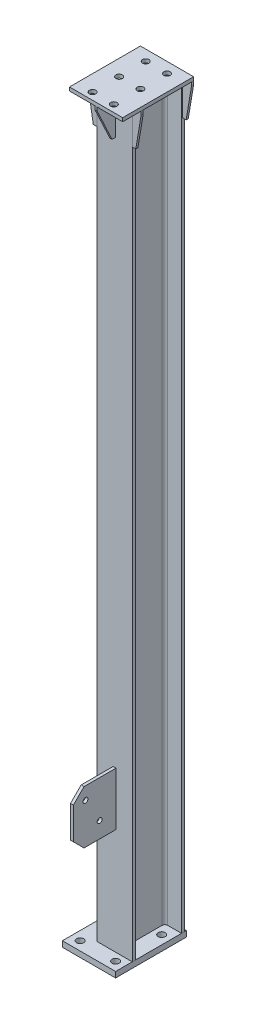
from build123d import *

# Parameters (mm, degrees)
H_HM150_100_1_DEPTH = 2100
SKETCH_12_W         = 150
SKETCH_12_H         = 200
EXTRUDE_1_DEPTH     = 16
SKETCH_13_W         = 148
SKETCH_13_H         = 10
CUT_EXTRUDE_1_DEPTH = 100
SKETCH_14_W         = 150
SKETCH_14_H         = 200
EXTRUDE_2_DEPTH     = 10
SKETCH_16_R         = 9
CUT_EXTRUDE_2_DEPTH = 10
EXTRUDE_3_DEPTH     = 6
EXTRUDE_3_2_DEPTH   = 6
EXTRUDE_4_DEPTH     = 6
EXTRUDE_4_2_DEPTH   = 6
EXTRUDE_5_DEPTH     = 6
SKETCH_20_W         = 8
SKETCH_20_H         = 150
EXTRUDE_6_DEPTH     = 120
CHAMFER_1_SIZE      = 30
SKETCH_21_R         = 7
CUT_EXTRUDE_3_DEPTH = 8
SKETCH_22_W         = 159
SKETCH_22_H         = 150
EXTRUDE_7_DEPTH     = 8
CHAMFER_2_SIZE      = 30
SKETCH_23_R         = 7
CUT_EXTRUDE_4_DEPTH = 8
SKETCH_24_R         = 10
CUT_EXTRUDE_5_DEPTH = 16


with BuildPart() as part:
    # 草图11 → H型钢 HM150×100(1) (new body)
    with BuildSketch(Plane(origin=(-50, -1126.815903712, 4951.12717578), x_dir=(1, 0, 0), z_dir=(0, -1, 0))):
        with BuildLine():
            Line((-50, -74), (50, -74))
            Line((50, -74), (50, -65))
            Line((50, -65), (11, -65))
            ThreePointArc((11, -65), (5.343145751, -62.656854249), (3, -57))
            Line((3, -57), (3, 57))
            ThreePointArc((3, 57), (5.343145751, 62.656854249), (11, 65))
            Line((11, 65), (50, 65))
            Line((50, 65), (50, 74))
            Line((50, 74), (-50, 74))
            Line((-50, 74), (-50, 65))
            Line((-50, 65), (-11, 65))
            ThreePointArc((-11, 65), (-5.343145751, 62.656854249), (-3, 57))
            Line((-3, 57), (-3, -57))
            ThreePointArc((-3, -57), (-5.343145751, -62.656854249), (-11, -65))
            Line((-11, -65), (-50, -65))
            Line((-50, -65), (-50, -74))
        make_face()
    extrude(amount=H_HM150_100_1_DEPTH)

    # 草图13 → 切除-拉伸1 (cut)
    with BuildSketch(Plane.ZY.offset(100)):
        with Locations((4951.12717578, -1131.815903712)):
            Rectangle(SKETCH_13_W, SKETCH_13_H)
    extrude(amount=-CUT_EXTRUDE_1_DEPTH, mode=Mode.SUBTRACT)


with BuildPart() as body_2:
    # 草图12 → 凸台-拉伸1 (new body)
    with BuildSketch(Plane.XZ.offset(3226.815903712)):
        with Locations((-75, 4972.12717578)):
            Rectangle(SKETCH_12_W, SKETCH_12_H)
    extrude(amount=EXTRUDE_1_DEPTH)

    # 草图24 → 切除-拉伸5 (cut)
    with BuildSketch(Plane.XZ.offset(3242.815903712)):
        with Locations(Location((-125, 5047.12717578, 0), (0, 0, 270))):
            Circle(SKETCH_24_R)
        with Locations(Location((-25, 5047.12717578, 0), (0, 0, 270))):
            Circle(SKETCH_24_R)
        with Locations(Location((-125, 4917.12717578, 0), (0, 0, 270))):
            Circle(SKETCH_24_R)
        with Locations(Location((-25, 4917.12717578, 0), (0, 0, 270))):
            Circle(SKETCH_24_R)
    extrude(amount=-CUT_EXTRUDE_5_DEPTH, mode=Mode.SUBTRACT)


with BuildPart() as body_3:
    # 草图14 → 凸台-拉伸2 (new body)
    with BuildSketch(Plane(origin=(0, -1136.815903712, 0), x_dir=(1, 0, 0), z_dir=(0, 1, 0))):
        with Locations((-50, -4977.12717578)):
            Rectangle(SKETCH_14_W, SKETCH_14_H)
    extrude(amount=EXTRUDE_2_DEPTH)

    # 草图16 → 切除-拉伸2 (cut)
    with BuildSketch(Plane(origin=(0, -1126.815903712, 0), x_dir=(1, 0, 0), z_dir=(0, 1, 0))):
        with Locations(Location((-20, -4907.12717578, 0), (0, 0, 270))):
            Circle(SKETCH_16_R)
        with Locations(Location((-20, -4982.12717578, 0), (0, 0, 270))):
            Circle(SKETCH_16_R)
        with Locations(Location((-20, -5057.12717578, 0), (0, 0, 270))):
            Circle(SKETCH_16_R)
        with Locations(Location((-80, -4907.12717578, 0), (0, 0, 270))):
            Circle(SKETCH_16_R)
        with Locations(Location((-80, -4982.12717578, 0), (0, 0, 270))):
            Circle(SKETCH_16_R)
        with Locations(Location((-80, -5057.12717578, 0), (0, 0, 270))):
            Circle(SKETCH_16_R)
    extrude(amount=-CUT_EXTRUDE_2_DEPTH, mode=Mode.SUBTRACT)


with BuildPart() as body_4:
    # 草图17 → 凸台-拉伸3 (new body)
    with BuildSketch(Plane(origin=(0, 0, 4877.12717578), x_dir=(-1, 0, 0), z_dir=(0, 0, -1))):
        Polygon((0, -1136.815903712), (-25, -1136.815903712), (-25, -1146.815903712), (-10, -1236.815903712), (0, -1236.815903712), align=None)
    extrude(amount=-EXTRUDE_3_DEPTH)


with BuildPart() as body_5:
    # 草图17 → Extrude 3 2 (new body)
    with BuildSketch(Plane(origin=(0, 0, 4877.12717578), x_dir=(-1, 0, 0), z_dir=(0, 0, -1))):
        Polygon((100, -1136.815903712), (125, -1136.815903712), (125, -1146.815903712), (110, -1236.815903712), (100, -1236.815903712), align=None)
    extrude(amount=-EXTRUDE_3_2_DEPTH)


with BuildPart() as body_6:
    # 草图18 → 凸台-拉伸4 (new body)
    with BuildSketch(Plane.XY.offset(5025.12717578)):
        Polygon((-100, -1236.815903712), (-100, -1136.815903712), (-125, -1136.815903712), (-125, -1146.815903712), (-110, -1236.815903712), align=None)
    extrude(amount=-EXTRUDE_4_DEPTH)


with BuildPart() as body_7:
    # 草图18 → Extrude 4 2 (new body)
    with BuildSketch(Plane.XY.offset(5025.12717578)):
        Polygon((0, -1136.815903712), (0, -1236.815903712), (10, -1236.815903712), (25, -1146.815903712), (25, -1136.815903712), align=None)
    extrude(amount=-EXTRUDE_4_2_DEPTH)


with BuildPart() as body_8:
    # 草图19 → 凸台-拉伸5 (new body)
    with BuildSketch(Plane(origin=(-47, 0, 0), x_dir=(0, 0, -1), z_dir=(1, 0, 0))):
        Polygon((-5025.12717578, -1136.815903712), (-5077.12717578, -1136.815903712), (-5077.12717578, -1146.815903712), (-5035.12717578, -1236.815903712), (-5025.12717578, -1236.815903712), align=None)
    extrude(amount=-EXTRUDE_5_DEPTH)


with BuildPart() as body_9:
    # 草图20 → 凸台-拉伸6 (new body)
    with BuildSketch(Plane.XY.offset(5025.12717578)):
        with Locations((-50, -2851.815903712)):
            Rectangle(SKETCH_20_W, SKETCH_20_H)
    extrude(amount=EXTRUDE_6_DEPTH)

    # 倒角1
    chamfer_1_edges = [body_9.edges().sort_by_distance(p)[0] for p in [
        (-50, -2776.815903712, 5145.12717578),
        (-50, -2926.815903712, 5145.12717578),
    ]]
    chamfer(chamfer_1_edges, length=CHAMFER_1_SIZE)

    # 草图21 → 切除-拉伸3 (cut)
    with BuildSketch(Plane(origin=(-46, 0, 0), x_dir=(0, 0, -1), z_dir=(1, 0, 0))):
        with Locations(Location((-5071.107937894, -2881.815903712, 0), (0, 0, 90))):
            Circle(SKETCH_21_R)
        with Locations(Location((-5111.107937894, -2812.533871409, 0), (0, 0, 90))):
            Circle(SKETCH_21_R)
    extrude(amount=-CUT_EXTRUDE_3_DEPTH, mode=Mode.SUBTRACT)


with BuildPart() as body_10:
    # 草图22 → 凸台-拉伸7 (new body)
    with BuildSketch(Plane.XY.offset(4886.12717578)):
        with Locations((-140.5, -2901.815903712)):
            Rectangle(SKETCH_22_W, SKETCH_22_H)
    extrude(amount=EXTRUDE_7_DEPTH)

    # 倒角2
    chamfer_2_edges = [body_10.edges().sort_by_distance(p)[0] for p in [
        (-220, -2976.815903712, 4890.12717578),
        (-220, -2826.815903712, 4890.12717578),
    ]]
    chamfer(chamfer_2_edges, length=CHAMFER_2_SIZE)

    # 草图23 → 切除-拉伸4 (cut)
    with BuildSketch(Plane.XY.offset(4894.12717578)):
        with Locations((-128.008301528, -2936.815903712)):
            Circle(SKETCH_23_R)
        with Locations((-173.894416436, -2871.283740168)):
            Circle(SKETCH_23_R)
    extrude(amount=-CUT_EXTRUDE_4_DEPTH, mode=Mode.SUBTRACT)


solid = Compound([part.part, body_2.part, body_3.part, body_4.part, body_5.part, body_6.part, body_7.part, body_8.part, body_9.part, body_10.part])
